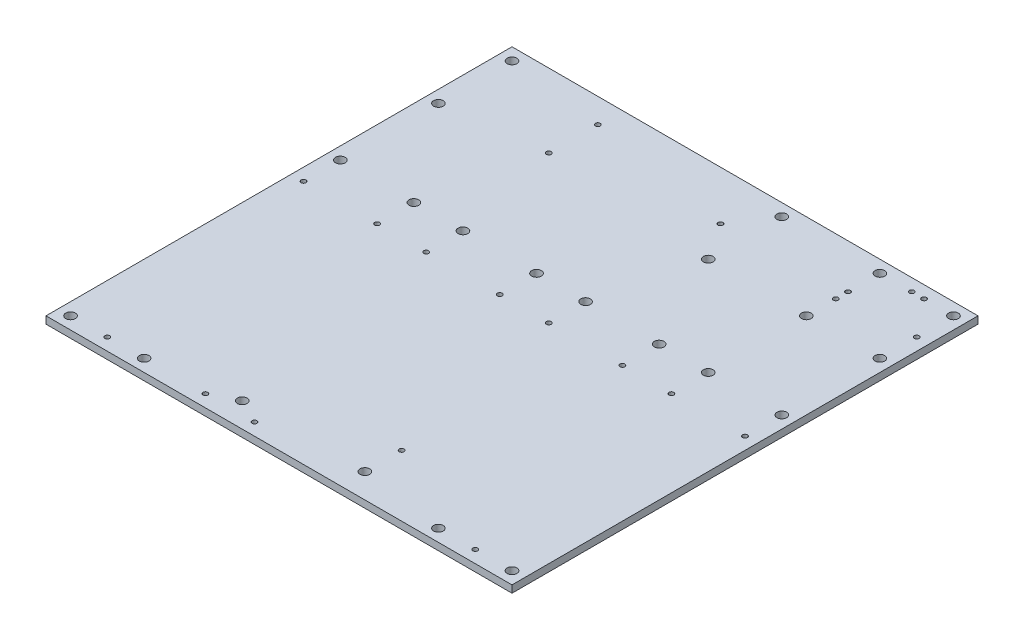
from build123d import *

# Parameters (mm, degrees)
SKETCH1_W           = 96.52
SKETCH1_H           = 96.52
SKETCH1_R           = 1
SKETCH1_R_2         = 0.5
BOSS_EXTRUDE1_DEPTH = 1.5
SKETCH1_3_R         = 0.5
BOSS_EXTRUDE2_DEPTH = 0.762


with BuildPart() as part:
    # Sketch1 → Boss-Extrude1 (new body)
    with BuildSketch(Plane(origin=(0, 0, 0), x_dir=(1, 0, 0), z_dir=(0, 1, 0))):
        with Locations((48.26, -27.94)):
            Rectangle(SKETCH1_W, SKETCH1_H)
        with Locations(Location((2.54, 2.54, 0), (0, 0, 270))):  # turned: the seam where the file's is
            Circle(SKETCH1_R, mode=Mode.SUBTRACT)
        with Locations(Location((22.86, 5.08, 0), (0, 0, 270))):  # turned: the seam where the file's is
            Circle(SKETCH1_R_2, mode=Mode.SUBTRACT)
        with Locations(Location((2.54, 17.78, 0), (0, 0, 270))):  # turned: the seam where the file's is
            Circle(SKETCH1_R, mode=Mode.SUBTRACT)
        with Locations(Location((22.86, 15.24, 0), (0, 0, 270))):  # turned: the seam where the file's is
            Circle(SKETCH1_R_2, mode=Mode.SUBTRACT)
        with Locations(Location((58.42, 2.54, 0), (0, 0, 270))):  # turned: the seam where the file's is
            Circle(SKETCH1_R, mode=Mode.SUBTRACT)
        with Locations(Location((53.34, 10.16, 0), (0, 0, 270))):  # turned: the seam where the file's is
            Circle(SKETCH1_R_2, mode=Mode.SUBTRACT)
        with Locations(Location((58.42, 17.78, 0), (0, 0, 270))):  # turned: the seam where the file's is
            Circle(SKETCH1_R, mode=Mode.SUBTRACT)
        with Locations(Location((17.78, -17.78, 0), (0, 0, 270))):  # turned: the seam where the file's is
            Circle(SKETCH1_R, mode=Mode.SUBTRACT)
        with Locations(Location((17.78, -25.4, 0), (0, 0, 270))):  # turned: the seam where the file's is
            Circle(SKETCH1_R_2, mode=Mode.SUBTRACT)
        with Locations(Location((2.54, -73.66, 0), (0, 0, 270))):  # turned: the seam where the file's is
            Circle(SKETCH1_R, mode=Mode.SUBTRACT)
        with Locations(Location((10.16, -73.66, 0), (0, 0, 270))):  # turned: the seam where the file's is
            Circle(SKETCH1_R_2, mode=Mode.SUBTRACT)
        with Locations(Location((17.78, -73.66, 0), (0, 0, 270))):  # turned: the seam where the file's is
            Circle(SKETCH1_R, mode=Mode.SUBTRACT)
        with Locations(Location((2.54, -25.4, 0), (0, 0, 270))):  # turned: the seam where the file's is
            Circle(SKETCH1_R_2, mode=Mode.SUBTRACT)
        with Locations(Location((2.54, -17.78, 0), (0, 0, 270))):  # turned: the seam where the file's is
            Circle(SKETCH1_R, mode=Mode.SUBTRACT)
        with Locations(Location((93.98, 17.78, 0), (0, 0, 270))):  # turned: the seam where the file's is
            Circle(SKETCH1_R, mode=Mode.SUBTRACT)
        with Locations(Location((87.884, 17.78, 0), (0, 0, 270))):  # turned: the seam where the file's is
            Circle(SKETCH1_R_2, mode=Mode.SUBTRACT)
        with Locations(Location((78.74, 2.54, 0), (0, 0, 270))):  # turned: the seam where the file's is
            Circle(SKETCH1_R, mode=Mode.SUBTRACT)
        with Locations(Location((93.98, 2.54, 0), (0, 0, 270))):  # turned: the seam where the file's is
            Circle(SKETCH1_R, mode=Mode.SUBTRACT)
        with Locations(Location((78.74, 8.636, 0), (0, 0, 270))):  # turned: the seam where the file's is
            Circle(SKETCH1_R_2, mode=Mode.SUBTRACT)
        with Locations(Location((78.74, 11.176, 0), (0, 0, 270))):  # turned: the seam where the file's is
            Circle(SKETCH1_R_2, mode=Mode.SUBTRACT)
        with Locations(Location((78.74, 17.78, 0), (0, 0, 270))):  # turned: the seam where the file's is
            Circle(SKETCH1_R, mode=Mode.SUBTRACT)
        with Locations(Location((93.98, 10.16, 0), (0, 0, 270))):  # turned: the seam where the file's is
            Circle(SKETCH1_R_2, mode=Mode.SUBTRACT)
        with Locations(Location((85.344, 17.78, 0), (0, 0, 270))):  # turned: the seam where the file's is
            Circle(SKETCH1_R_2, mode=Mode.SUBTRACT)
        with Locations(Location((43.18, -17.78, 0), (0, 0, 270))):  # turned: the seam where the file's is
            Circle(SKETCH1_R, mode=Mode.SUBTRACT)
        with Locations(Location((43.18, -25.4, 0), (0, 0, 270))):  # turned: the seam where the file's is
            Circle(SKETCH1_R_2, mode=Mode.SUBTRACT)
        with Locations(Location((27.94, -17.78, 0), (0, 0, 270))):  # turned: the seam where the file's is
            Circle(SKETCH1_R, mode=Mode.SUBTRACT)
        with Locations(Location((30.48, -73.66, 0), (0, 0, 270))):  # turned: the seam where the file's is
            Circle(SKETCH1_R_2, mode=Mode.SUBTRACT)
        with Locations(Location((35.56, -71.12, 0), (0, 0, 270))):  # turned: the seam where the file's is
            Circle(SKETCH1_R, mode=Mode.SUBTRACT)
        with Locations(Location((40.64, -73.66, 0), (0, 0, 270))):  # turned: the seam where the file's is
            Circle(SKETCH1_R_2, mode=Mode.SUBTRACT)
        with Locations(Location((27.94, -25.4, 0), (0, 0, 270))):  # turned: the seam where the file's is
            Circle(SKETCH1_R_2, mode=Mode.SUBTRACT)
        with Locations(Location((93.98, -17.78, 0), (0, 0, 270))):  # turned: the seam where the file's is
            Circle(SKETCH1_R, mode=Mode.SUBTRACT)
        with Locations(Location((93.98, -25.4, 0), (0, 0, 270))):  # turned: the seam where the file's is
            Circle(SKETCH1_R_2, mode=Mode.SUBTRACT)
        with Locations(Location((78.74, -73.66, 0), (0, 0, 270))):  # turned: the seam where the file's is
            Circle(SKETCH1_R, mode=Mode.SUBTRACT)
        with Locations(Location((86.36, -73.66, 0), (0, 0, 270))):  # turned: the seam where the file's is
            Circle(SKETCH1_R_2, mode=Mode.SUBTRACT)
        with Locations(Location((93.98, -73.66, 0), (0, 0, 270))):  # turned: the seam where the file's is
            Circle(SKETCH1_R, mode=Mode.SUBTRACT)
        with Locations(Location((78.74, -25.4, 0), (0, 0, 270))):  # turned: the seam where the file's is
            Circle(SKETCH1_R_2, mode=Mode.SUBTRACT)
        with Locations(Location((78.74, -17.78, 0), (0, 0, 270))):  # turned: the seam where the file's is
            Circle(SKETCH1_R, mode=Mode.SUBTRACT)
        with Locations(Location((68.58, -17.78, 0), (0, 0, 270))):  # turned: the seam where the file's is
            Circle(SKETCH1_R, mode=Mode.SUBTRACT)
        with Locations(Location((68.58, -25.4, 0), (0, 0, 270))):  # turned: the seam where the file's is
            Circle(SKETCH1_R_2, mode=Mode.SUBTRACT)
        with Locations(Location((53.34, -17.78, 0), (0, 0, 270))):  # turned: the seam where the file's is
            Circle(SKETCH1_R, mode=Mode.SUBTRACT)
        with Locations(Location((60.96, -71.12, 0), (0, 0, 270))):  # turned: the seam where the file's is
            Circle(SKETCH1_R, mode=Mode.SUBTRACT)
        with Locations(Location((60.96, -63.5, 0), (0, 0, 270))):  # turned: the seam where the file's is
            Circle(SKETCH1_R_2, mode=Mode.SUBTRACT)
        with Locations(Location((53.34, -25.4, 0), (0, 0, 270))):  # turned: the seam where the file's is
            Circle(SKETCH1_R_2, mode=Mode.SUBTRACT)
    extrude(amount=BOSS_EXTRUDE1_DEPTH)

    # Sketch1_3 → Boss-Extrude2 (add)
    with BuildSketch(Plane(origin=(0, 0, 0), x_dir=(1, 0, 0), z_dir=(0, 1, 0))):
        with Locations(Location((78.74, 8.636, 0), (0, 0, 270))):  # turned: the seam where the file's is
            Circle(SKETCH1_3_R)
        with Locations(Location((78.74, 11.176, 0), (0, 0, 270))):  # turned: the seam where the file's is
            Circle(SKETCH1_3_R)
        with Locations(Location((85.344, 17.78, 0), (0, 0, 270))):  # turned: the seam where the file's is
            Circle(SKETCH1_3_R)
        with Locations(Location((87.884, 17.78, 0), (0, 0, 270))):  # turned: the seam where the file's is
            Circle(SKETCH1_3_R)
    extrude(amount=BOSS_EXTRUDE2_DEPTH)


solid = part.part
